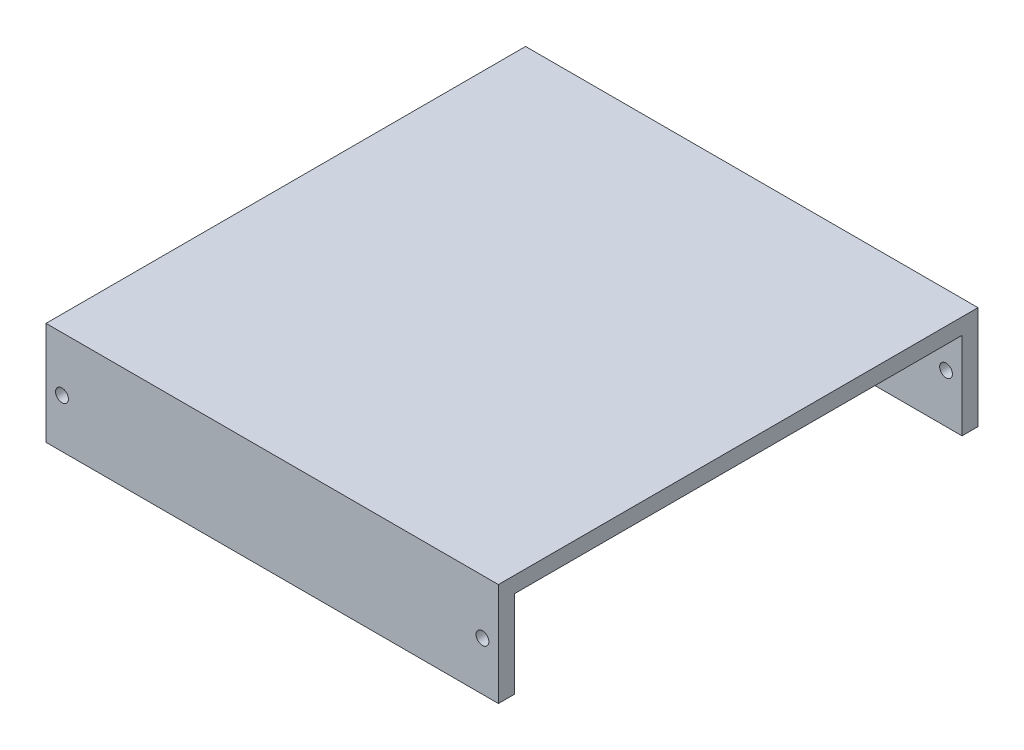
from build123d import *

# Parameters (mm, degrees)
SKETCH_2_R      = 4
EXTRUDE_1_DEPTH = 10
SKETCH_3_W      = 283
SKETCH_3_H      = 10
EXTRUDE_5_DEPTH = 300
SKETCH_6_W      = 283
SKETCH_6_H      = 64.47
SKETCH_6_R      = 4
EXTRUDE_7_DEPTH = 10


with BuildPart() as part:
    # 草图2 → 凸台-拉伸1 (new body)
    with BuildSketch(Plane.XY):
        Polygon((212.655000043, 48), (-50.344999957, 48), (-60.344999957, 48), (-60.344999957, -3.53), (-60.344999957, -6.47), (222.655000043, -6.47), (222.655000043, -3.53), (222.655000043, 48), align=None)
        with Locations((212.655000043, 24)):
            Circle(SKETCH_2_R, mode=Mode.SUBTRACT)
        with Locations((-50.344999957, 24)):
            Circle(SKETCH_2_R, mode=Mode.SUBTRACT)
    extrude(amount=EXTRUDE_1_DEPTH)

    # 草图3 → 凸台-拉伸5 (add)
    with BuildSketch(Plane.XY):
        with Locations((81.155000043, 53)):
            Rectangle(SKETCH_3_W, SKETCH_3_H)
    extrude(amount=EXTRUDE_5_DEPTH)

    # 草图6 → 凸台-拉伸7 (add)
    with BuildSketch(Plane.XY.offset(300)):
        with Locations((81.155000043, 25.765)):
            Rectangle(SKETCH_6_W, SKETCH_6_H)
        with Locations((-50.344999957, 24)):
            Circle(SKETCH_6_R, mode=Mode.SUBTRACT)
        with Locations((212.655000043, 24)):
            Circle(SKETCH_6_R, mode=Mode.SUBTRACT)
    extrude(amount=-EXTRUDE_7_DEPTH)


solid = part.part
